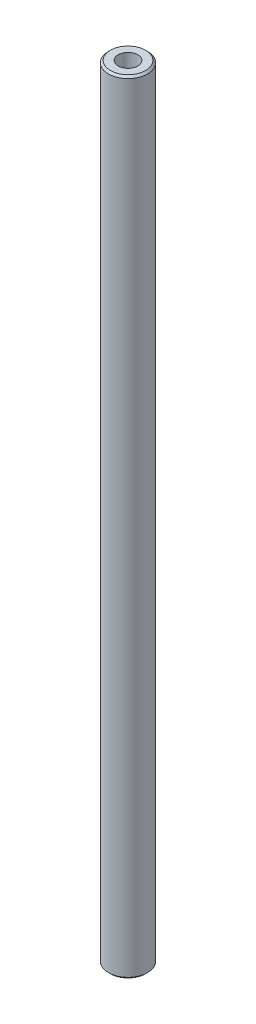
from build123d import *

# Parameters (mm, degrees)
ESQUISSE1_R      = 5
EXTRUSION1_DEPTH = 200
CHANFREIN1_SIZE  = 0.5
ESQUISSE2_R      = 2.5
EXTRUSION2_DEPTH = 15
ESQUISSE3_R      = 2.5
EXTRUSION3_DEPTH = 15


with BuildPart() as part:
    # Esquisse1 → Extrusion1 (new body)
    with BuildSketch(Plane(origin=(0, 0, 0), x_dir=(1, 0, 0), z_dir=(0, 1, 0))):
        Circle(ESQUISSE1_R)
    extrude(amount=EXTRUSION1_DEPTH)

    # Chanfrein1
    chanfrein1_edges = [part.edges().sort_by_distance(p)[0] for p in [
        (-5, 0, 0),
        (-5, 200, 0),
    ]]
    chamfer(chanfrein1_edges, length=CHANFREIN1_SIZE)

    # Esquisse2 → Extrusion2 (cut)
    with BuildSketch(Plane.XZ):
        Circle(ESQUISSE2_R)
    extrude(amount=-EXTRUSION2_DEPTH, mode=Mode.SUBTRACT)

    # Esquisse3 → Extrusion3 (cut)
    with BuildSketch(Plane(origin=(0, 200, 0), x_dir=(1, 0, 0), z_dir=(0, 1, 0))):
        Circle(ESQUISSE3_R)
    extrude(amount=-EXTRUSION3_DEPTH, mode=Mode.SUBTRACT)


solid = part.part
